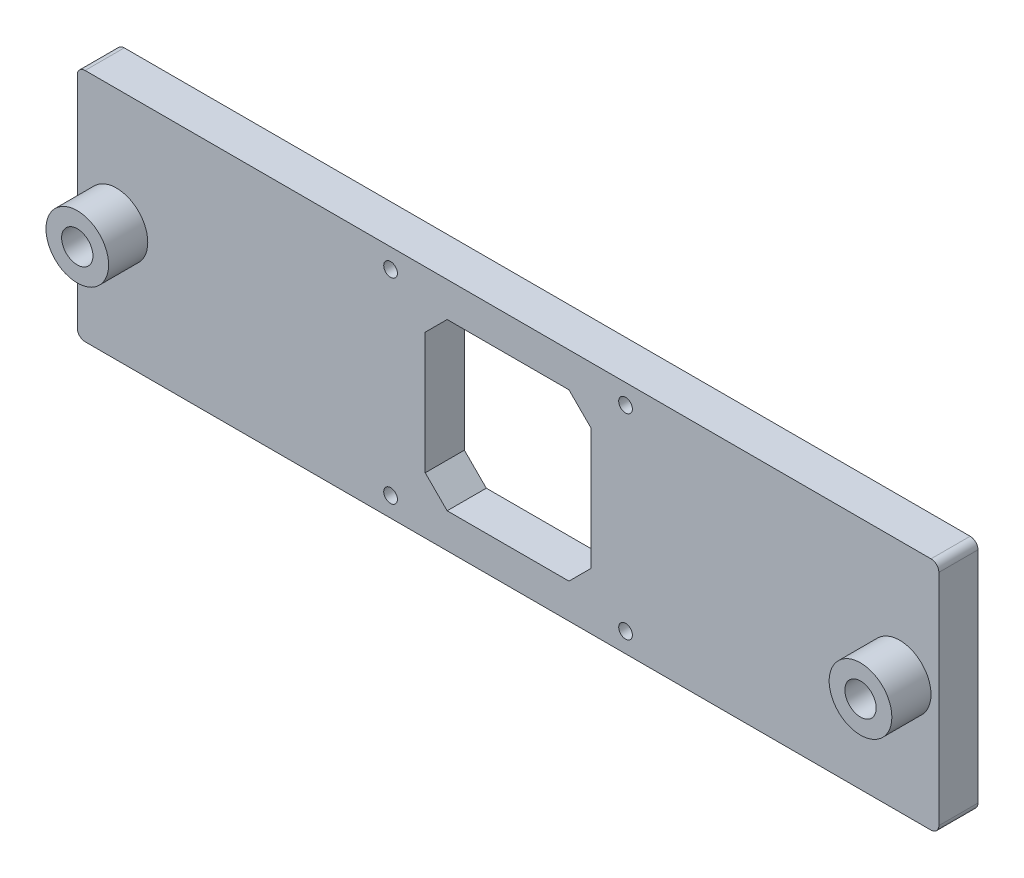
from build123d import *

# Parameters (mm, degrees)
ESBO_O1_W                = 220
ESBO_O1_H                = 60
ESBO_O1_R                = 4
ESBO_O1_W_2              = 42.3
ESBO_O1_H_2              = 42.3
RESSALTO_EXTRUS_O1_DEPTH = 5
CHANFRO1_SIZE            = 5.6002
ESBO_O2_R                = 8
ESBO_O2_R_2              = 4
RESSALTO_EXTRUS_O2_DEPTH = 10
ESBO_O3_R                = 1.75
CORTE_EXTRUS_O1_DEPTH    = 10
FILETE1_R                = 2


with BuildPart() as part:
    # Esboço1 → Ressalto-extrusão1 (new body, symmetric)
    with BuildSketch(Plane.XY):
        Rectangle(ESBO_O1_W, ESBO_O1_H)
        with Locations((100, 0)):
            Circle(ESBO_O1_R, mode=Mode.SUBTRACT)
        with Locations((-100, 0)):
            Circle(ESBO_O1_R, mode=Mode.SUBTRACT)
        Rectangle(ESBO_O1_W_2, ESBO_O1_H_2, mode=Mode.SUBTRACT)
    extrude(amount=RESSALTO_EXTRUS_O1_DEPTH, both=True)

    # Chanfro1
    chanfro1_edges = [part.edges().sort_by_distance(p)[0] for p in [
        (21.15, -21.15, 0),
        (21.15, 21.15, 0),
        (-21.15, 21.15, 0),
        (-21.15, -21.15, 0),
    ]]
    chamfer(chanfro1_edges, length=CHANFRO1_SIZE)

    # Esboço2 → Ressalto-extrusão2 (add)
    with BuildSketch(Plane.XY.offset(5)):
        with Locations((-100, 0)):
            Circle(ESBO_O2_R)
        with Locations((-100, 0)):
            Circle(ESBO_O2_R_2, mode=Mode.SUBTRACT)
        with Locations((100, 0)):
            Circle(ESBO_O2_R)
        with Locations((100, 0)):
            Circle(ESBO_O2_R_2, mode=Mode.SUBTRACT)
    extrude(amount=RESSALTO_EXTRUS_O2_DEPTH)

    # Esboço3 → Corte-extrusão1 (cut)
    with BuildSketch(Plane.XY.offset(5)):
        with Locations((-30, 25)):
            Circle(ESBO_O3_R)
        with Locations((-30, -25)):
            Circle(ESBO_O3_R)
        with Locations((30, 25)):
            Circle(ESBO_O3_R)
        with Locations((30, -25)):
            Circle(ESBO_O3_R)
    extrude(amount=-CORTE_EXTRUS_O1_DEPTH, mode=Mode.SUBTRACT)

    # Filete1
    filete1_edges = [part.edges().sort_by_distance(p)[0] for p in [
        (110, -30, 0),
        (-110, -30, 0),
        (-110, 30, 0),
        (110, 30, 0),
    ]]
    fillet(filete1_edges, radius=FILETE1_R)


solid = part.part
